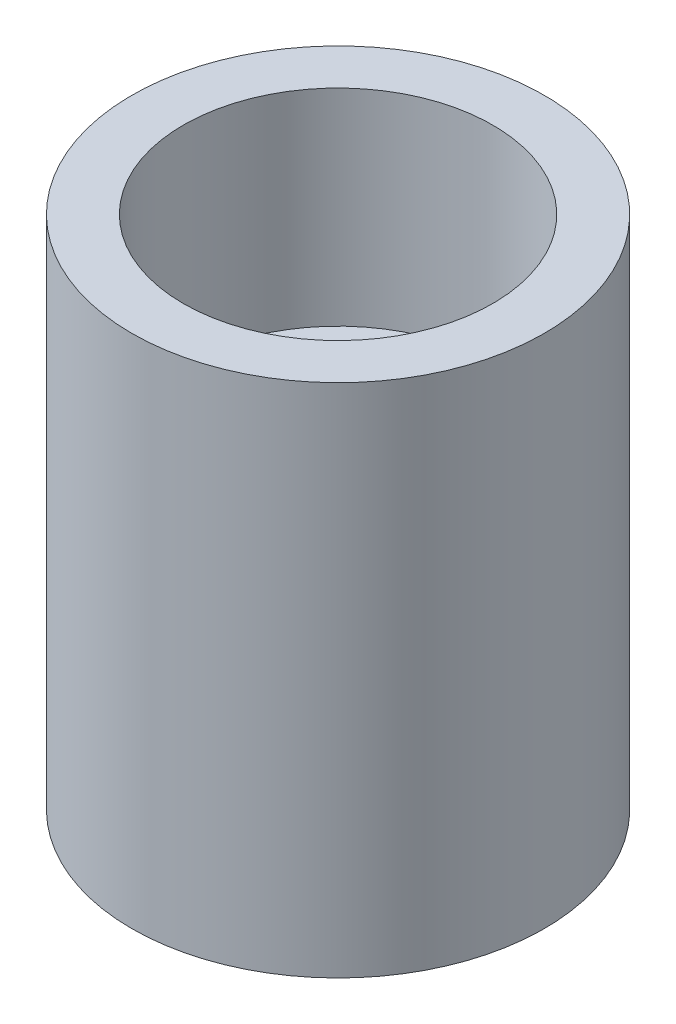
from build123d import *

# Parameters (mm, degrees)
SKETCH1_R           = 2
BOSS_EXTRUDE1_DEPTH = 5
SKETCH2_R           = 1.5
CUT_EXTRUDE1_DEPTH  = 2


with BuildPart() as part:
    # Sketch1 → Boss-Extrude1 (new body)
    with BuildSketch(Plane(origin=(0, 0, 0), x_dir=(1, 0, 0), z_dir=(0, 1, 0))):
        Circle(SKETCH1_R)
    extrude(amount=BOSS_EXTRUDE1_DEPTH)

    # Sketch2 → Cut-Extrude1 (cut)
    with BuildSketch(Plane(origin=(0, 5, 0), x_dir=(1, 0, 0), z_dir=(0, 1, 0))):
        Circle(SKETCH2_R)
    extrude(amount=-CUT_EXTRUDE1_DEPTH, mode=Mode.SUBTRACT)


solid = part.part
